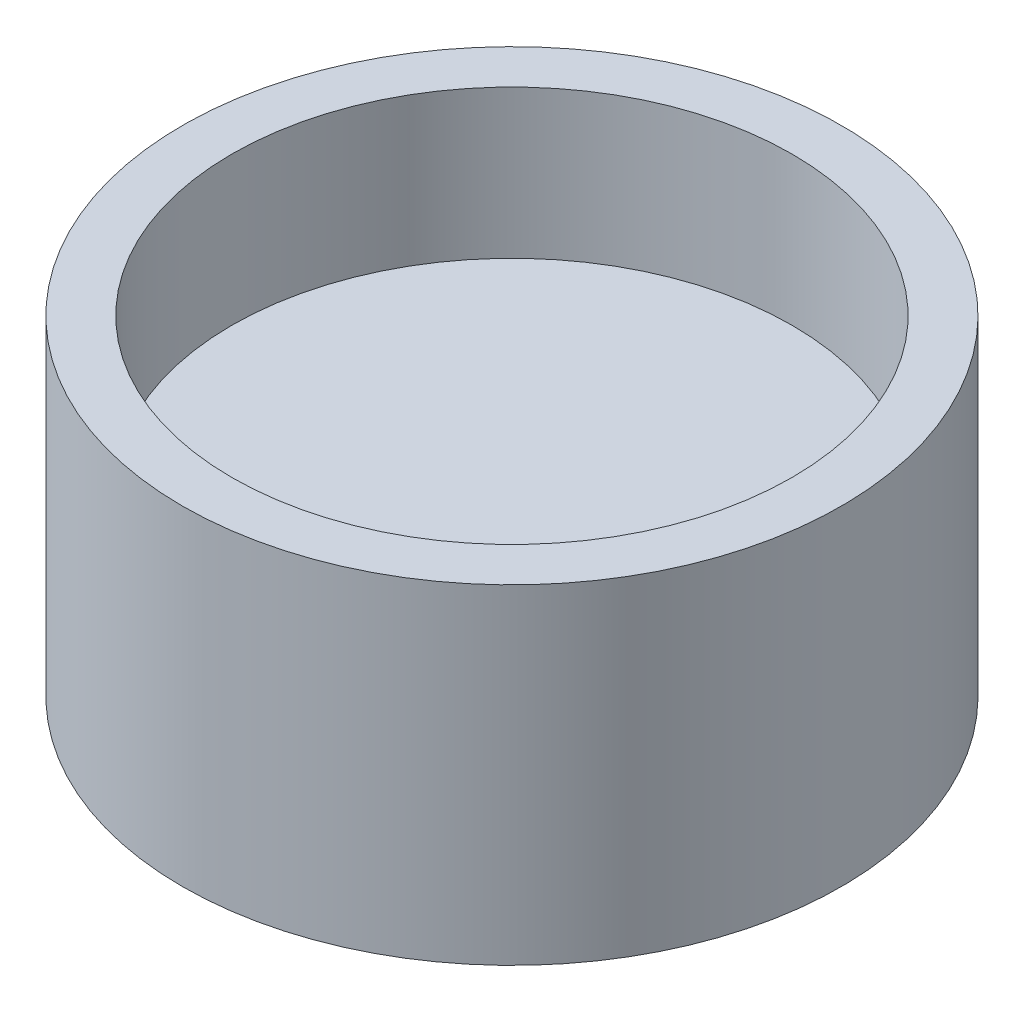
from build123d import *

# Parameters (mm, degrees)
SKETCH1_R           = 4
BOSS_EXTRUDE1_DEPTH = 4
SKETCH2_R           = 3.4
CUT_EXTRUDE1_DEPTH  = 1.8


with BuildPart() as part:
    # Sketch1 → Boss-Extrude1 (new body)
    with BuildSketch(Plane(origin=(0, 0, 0), x_dir=(1, 0, 0), z_dir=(0, 1, 0))):
        Circle(SKETCH1_R)
    extrude(amount=BOSS_EXTRUDE1_DEPTH)

    # Sketch2 → Cut-Extrude1 (cut)
    with BuildSketch(Plane(origin=(0, 4, 0), x_dir=(1, 0, 0), z_dir=(0, 1, 0))):
        Circle(SKETCH2_R)
    extrude(amount=-CUT_EXTRUDE1_DEPTH, mode=Mode.SUBTRACT)


solid = part.part
